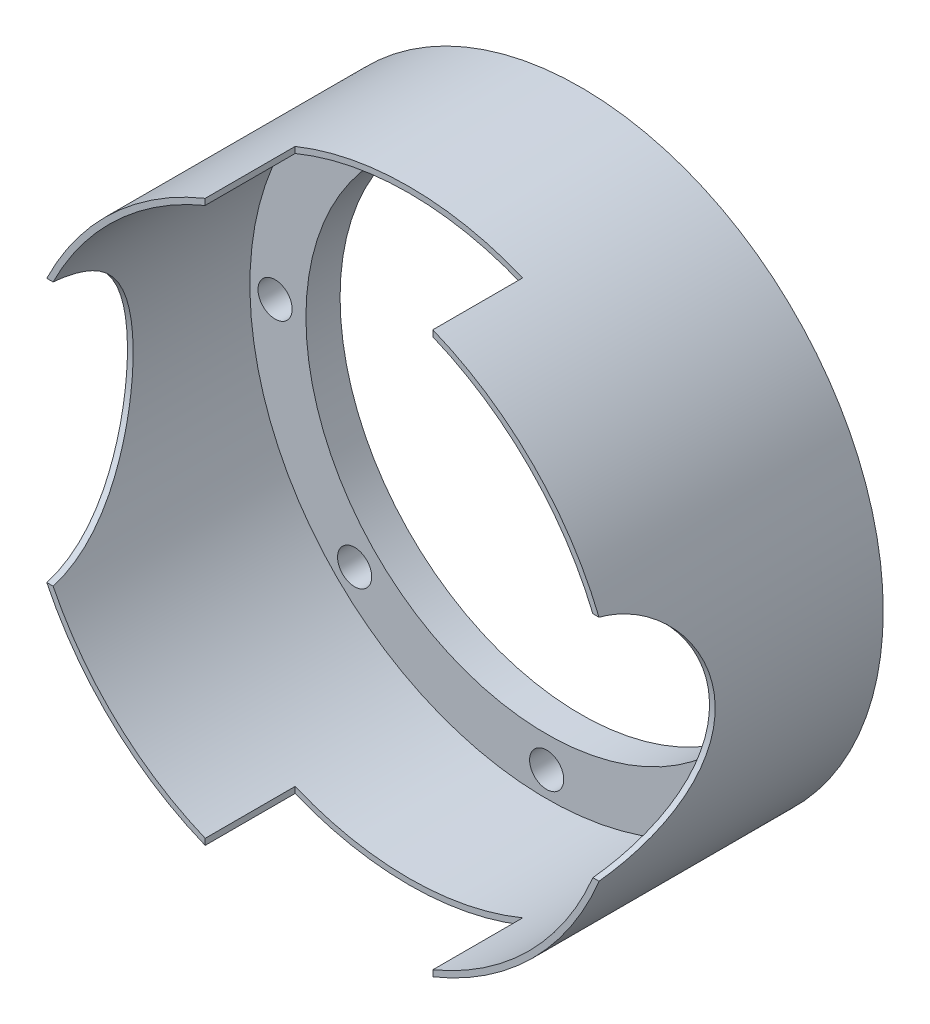
from build123d import *

# Parameters (mm, degrees)
SKETCH1_R           = 265.7
SKETCH1_R_2         = 211.5
SKETCH1_R_3         = 20
SKETCH1_R_4         = 5
EXTRUDE1_DEPTH      = 5
SKETCH2_R           = 265.7
SKETCH2_R_2         = 15
SKETCH2_R_3         = 211.5
EXTRUDE2_DEPTH      = 25
SKETCH3_R           = 265.7
SKETCH3_R_2         = 260.7
EXTRUDE3_DEPTH      = 200
SKETCH4_R           = 102.37
EXTRUDE4_DEPTH      = 266.7
SKETCH5_R           = 117.4
EXTRUDE5_DEPTH      = 266.7000001
SKETCH6_W           = 200
SKETCH6_H           = 79
EXTRUDE6_DEPTH      = 266.7000001
EXTRUDE6_DEPTH_BACK = 266.7000001


with BuildPart() as part:
    # Sketch1 → Extrude1 (new body)
    with BuildSketch(Plane.XY):
        Circle(SKETCH1_R)
        Circle(SKETCH1_R_2, mode=Mode.SUBTRACT)
        with Locations((238.6, 0)):
            Circle(SKETCH1_R_3, mode=Mode.SUBTRACT)
        with Locations((168.715677991, 168.715677991)):
            Circle(SKETCH1_R_3, mode=Mode.SUBTRACT)
        with Locations((0, 238.6)):
            Circle(SKETCH1_R_3, mode=Mode.SUBTRACT)
        with Locations((-168.715677991, 168.715677991)):
            Circle(SKETCH1_R_3, mode=Mode.SUBTRACT)
        with Locations((-238.6, 0)):
            Circle(SKETCH1_R_3, mode=Mode.SUBTRACT)
        with Locations((-168.715677991, -168.715677991)):
            Circle(SKETCH1_R_3, mode=Mode.SUBTRACT)
        with Locations((0, -238.6)):
            Circle(SKETCH1_R_3, mode=Mode.SUBTRACT)
        with Locations((168.715677991, -168.715677991)):
            Circle(SKETCH1_R_3, mode=Mode.SUBTRACT)
        with Locations((230.469902153, 61.754224161)):
            Circle(SKETCH1_R_4, mode=Mode.SUBTRACT)
        with Locations((-230.469902153, 61.754224161)):
            Circle(SKETCH1_R_4, mode=Mode.SUBTRACT)
        with Locations((-91.308266962, -220.437656457)):
            Circle(SKETCH1_R_4, mode=Mode.SUBTRACT)
    extrude(amount=EXTRUDE1_DEPTH)

    # Sketch2 → Extrude2 (add)
    with BuildSketch(Plane.XY.offset(5)):
        Circle(SKETCH2_R)
        with Locations((238.6, 0)):
            Circle(SKETCH2_R_2, mode=Mode.SUBTRACT)
        with Locations((168.715677991, 168.715677991)):
            Circle(SKETCH2_R_2, mode=Mode.SUBTRACT)
        with Locations((0, 238.6)):
            Circle(SKETCH2_R_2, mode=Mode.SUBTRACT)
        with Locations((-168.715677991, 168.715677991)):
            Circle(SKETCH2_R_2, mode=Mode.SUBTRACT)
        with Locations((-238.6, 0)):
            Circle(SKETCH2_R_2, mode=Mode.SUBTRACT)
        with Locations((-168.715677991, -168.715677991)):
            Circle(SKETCH2_R_2, mode=Mode.SUBTRACT)
        with Locations((0, -238.6)):
            Circle(SKETCH2_R_2, mode=Mode.SUBTRACT)
        with Locations((168.715677991, -168.715677991)):
            Circle(SKETCH2_R_2, mode=Mode.SUBTRACT)
        Circle(SKETCH2_R_3, mode=Mode.SUBTRACT)
    extrude(amount=EXTRUDE2_DEPTH)

    # Sketch3 → Extrude3 (add)
    with BuildSketch(Plane.XY.offset(30)):
        Circle(SKETCH3_R)
        Circle(SKETCH3_R_2, mode=Mode.SUBTRACT)
    extrude(amount=EXTRUDE3_DEPTH)

    # Sketch4 → Extrude4 (cut, through all)
    with BuildSketch(Plane(origin=(0, 0, 0), x_dir=(0, 0, -1), z_dir=(1, 0, 0))):
        with Locations((-250, 0)):
            Circle(SKETCH4_R)
    extrude(amount=EXTRUDE4_DEPTH, mode=Mode.SUBTRACT)

    # Sketch5 → Extrude5 (cut, through all)
    with BuildSketch(Plane(origin=(0, 0, 0), x_dir=(0, 0, -1), z_dir=(1, 0, 0))):
        with Locations((-250, 0)):
            Circle(SKETCH5_R)
    extrude(amount=-EXTRUDE5_DEPTH, mode=Mode.SUBTRACT)

    # Sketch6 → Extrude6 (cut, two sides)
    with BuildSketch(Plane(origin=(0, 0, 0), x_dir=(1, 0, 0), z_dir=(0, 1, 0))) as extrude6_sk:
        with Locations((0, -190.5)):
            Rectangle(SKETCH6_W, SKETCH6_H)
    extrude(amount=EXTRUDE6_DEPTH, mode=Mode.SUBTRACT)
    extrude(extrude6_sk.sketch, amount=-EXTRUDE6_DEPTH_BACK, mode=Mode.SUBTRACT)


solid = part.part
